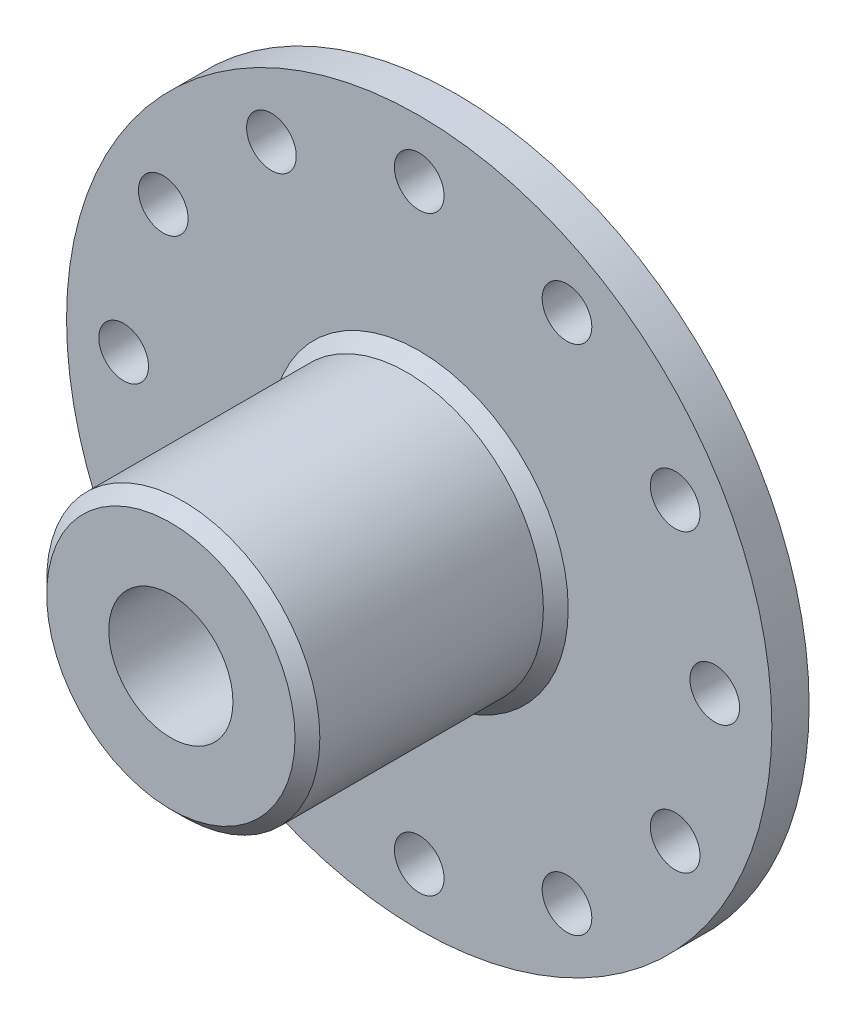
from build123d import *

# Parameters (mm, degrees)
SKETCH1_R           = 28.4
BOSS_EXTRUDE1_DEPTH = 3
SKETCH2_R           = 11
BOSS_EXTRUDE2_DEPTH = 20
SKETCH3_R           = 5
CUT_EXTRUDE1_DEPTH  = 24
SKETCH4_R           = 2
CUT_EXTRUDE2_DEPTH  = 15
CHAMFER1_SIZE       = 1
SKETCH5_R           = 2
CUT_EXTRUDE5_DEPTH  = 4.0000001
CIRPATTERN2_COUNT   = 12


with BuildPart() as part:
    # Sketch1 → Boss-Extrude1 (new body)
    with BuildSketch(Plane.XY):
        Circle(SKETCH1_R)
    extrude(amount=BOSS_EXTRUDE1_DEPTH)

    # Sketch2 → Boss-Extrude2 (add)
    with BuildSketch(Plane.XY.offset(3)):
        Circle(SKETCH2_R)
    extrude(amount=BOSS_EXTRUDE2_DEPTH)

    # Sketch3 → Cut-Extrude1 (cut, through all)
    with BuildSketch(Plane.XY.offset(23)):
        Circle(SKETCH3_R)
    extrude(amount=-CUT_EXTRUDE1_DEPTH, mode=Mode.SUBTRACT)

    # Sketch4 → Cut-Extrude2 (cut)
    with BuildSketch(Plane(origin=(0, 0, 0), x_dir=(1, 0, 0), z_dir=(0, 1, 0))):
        with Locations((0, -15)):
            Circle(SKETCH4_R)
    extrude(amount=-CUT_EXTRUDE2_DEPTH, mode=Mode.SUBTRACT)

    # Chamfer1
    chamfer1_edges = [part.edges().sort_by_distance(p)[0] for p in [
        (-11, 0, 3),
        (-11, 0, 23),
    ]]
    chamfer(chamfer1_edges, length=CHAMFER1_SIZE)

    # Sketch5 → Cut-Extrude5 (cut, through all)
    with BuildSketch(Plane.XY.offset(3)):
        with Locations((11.9, 20.61140461)):
            Circle(SKETCH5_R)
    cut_extrude5 = extrude(amount=-CUT_EXTRUDE5_DEPTH, mode=Mode.SUBTRACT)

    # CirPattern2: Cut-Extrude5 ×12 about axis
    cirpattern2_axis = Axis((0, 0, 0), (0, 0, 1))
    for i in range(1, CIRPATTERN2_COUNT):
        add(cut_extrude5.rotate(cirpattern2_axis, i * 360 / CIRPATTERN2_COUNT), mode=Mode.SUBTRACT)


solid = part.part
